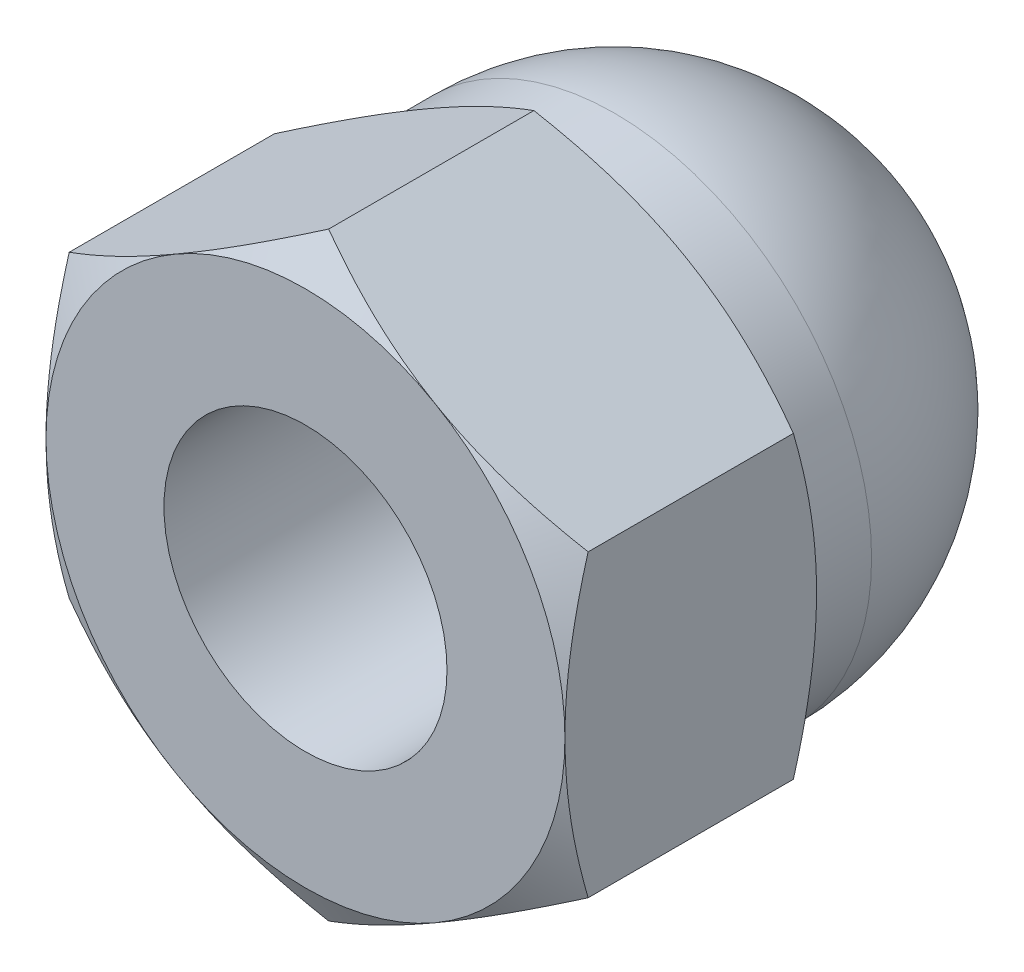
from build123d import *

# Parameters (mm, degrees)
EXTRUDE1_DEPTH     = 2.666666667
SKETCH2_OUTSIDE_W  = 21.964
SKETCH2_OUTSIDE_H  = 22.814
SKETCH2_OUTSIDE_R  = 2.75
CUT_EXTRUDE1_DEPTH = 3.666666667
CUT_EXTRUDE1_TAPER = 60
SKETCH3_OUTSIDE_W  = 21.964
SKETCH3_OUTSIDE_H  = 22.814
SKETCH3_OUTSIDE_R  = 2.75
CUT_EXTRUDE2_DEPTH = 3.666666667
CUT_EXTRUDE2_TAPER = 60
SKETCH4_R          = 1.5
CUT_EXTRUDE3_DEPTH = 3.8


with BuildPart() as part:
    # Sketch1 → Extrude1 (new body)
    with BuildSketch(Plane.XY):
        Polygon((0, 3.175426481), (-2.75, 1.58771324), (-2.75, -1.58771324), (0, -3.175426481), (2.75, -1.58771324), (2.75, 1.58771324), align=None)
    extrude(amount=-EXTRUDE1_DEPTH)

    # Sketch2 outside → Cut-Extrude1 (cut, through all)
    with BuildSketch(Plane.XY):
        Rectangle(SKETCH2_OUTSIDE_W, SKETCH2_OUTSIDE_H)
        Circle(SKETCH2_OUTSIDE_R, mode=Mode.SUBTRACT)
    extrude(amount=-CUT_EXTRUDE1_DEPTH, taper=CUT_EXTRUDE1_TAPER, mode=Mode.SUBTRACT)

    # Sketch3 outside → Cut-Extrude2 (cut, through all)
    with BuildSketch(Plane(origin=(0, 0, -2.666666667), x_dir=(-1, 0, 0), z_dir=(0, 0, -1))):
        Rectangle(SKETCH3_OUTSIDE_W, SKETCH3_OUTSIDE_H)
        Circle(SKETCH3_OUTSIDE_R, mode=Mode.SUBTRACT)
    extrude(amount=-CUT_EXTRUDE2_DEPTH, taper=CUT_EXTRUDE2_TAPER, mode=Mode.SUBTRACT)

    # Sketch14 → Revolve1 (revolve)
    with BuildSketch(Plane(origin=(0, 0, 0), x_dir=(0, 0, -1), z_dir=(1, 0, 0))):
        with BuildLine():
            Line((2.666666667, 2.7225), (2.666666667, 0))
            Line((2.666666667, 0), (6, 0))
            ThreePointArc((6, 0), (5.202598212, 1.925098212), (3.2775, 2.7225))
            Line((3.2775, 2.7225), (2.666666667, 2.7225))
        make_face()
    revolve(axis=Axis((0, 0, 0), (0, 0, -1)))

    # Sketch4 → Cut-Extrude3 (cut)
    with BuildSketch(Plane.XY):
        Circle(SKETCH4_R)
    extrude(amount=-CUT_EXTRUDE3_DEPTH, mode=Mode.SUBTRACT)


solid = part.part
